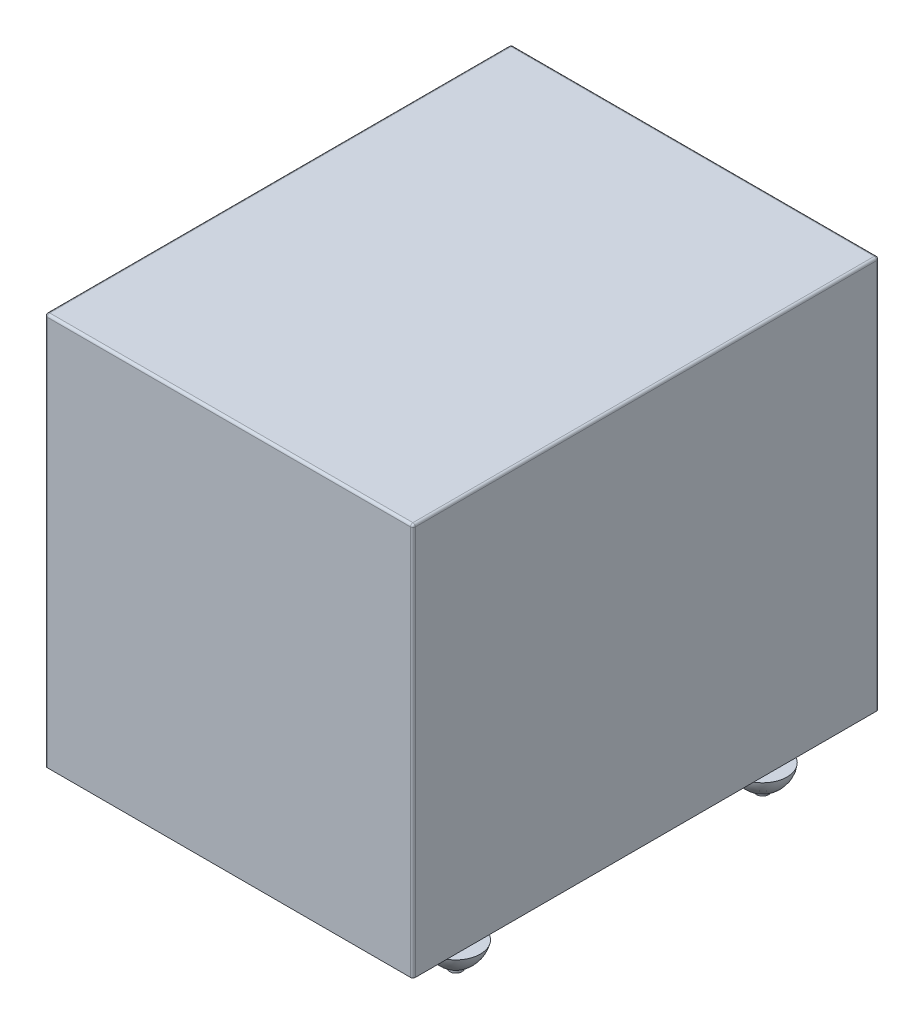
from build123d import *

# Parameters (mm, degrees)
IZIM1_W                     = 15
IZIM1_H                     = 19
Y_KSEKLIK_EKSTR_ZYON1_DEPTH = 16
RADYUS1_R                   = 0.1
IZIM2_R                     = 0.25
Y_KSEKLIK_EKSTR_ZYON2_DEPTH = 2


with BuildPart() as part:
    # Çizim1 → Yükseklik-Ekstrüzyon1 (new body)
    with BuildSketch(Plane(origin=(0, 0, 0), x_dir=(1, 0, 0), z_dir=(0, 1, 0))):
        Rectangle(IZIM1_W, IZIM1_H)
    extrude(amount=Y_KSEKLIK_EKSTR_ZYON1_DEPTH)

    # Radyus1
    radyus1_edges = [part.edges().sort_by_distance(p)[0] for p in [
        (-7.5, 16, 0),
        (0, 16, 9.5),
        (7.5, 16, 0),
        (0, 16, -9.5),
        (7.5, 8, 9.5),
        (-7.5, 8, 9.5),
        (-7.5, 8, -9.5),
        (7.5, 8, -9.5),
    ]]
    fillet(radyus1_edges, radius=RADYUS1_R)

    # Çizim2 → Yükseklik-Ekstrüzyon2 (add)
    with BuildSketch(Plane.XZ):
        with Locations((6, 6.25)):
            Circle(IZIM2_R)
        with Locations((-6, 6.25)):
            Circle(IZIM2_R)
        with Locations((6, -6.25)):
            Circle(IZIM2_R)
        with Locations((-6, -6.25)):
            Circle(IZIM2_R)
        with Locations((0, -8.25)):
            Circle(IZIM2_R)
    extrude(amount=Y_KSEKLIK_EKSTR_ZYON2_DEPTH)

    # Çizim3 → Döndür1 (revolve)
    with BuildSketch(Plane.ZY.offset(6)):
        with BuildLine():
            Line((-6.25, -2), (-6.25, -1))
            Line((-6.25, -1), (-5.25, -1))
            add(Edge.make_bspline(
                [(-6.25, -2), (-5.440038175, -1.628390392), (-5.25, -1)],
                knots=[0, 0, 0, 0.619923651, 0.619923651, 0.619923651], degree=2))
        make_face()
    revolve(axis=Axis((-6, -2, -6.25), (0, 1, 0)))

    # Çizim4 → Döndür2 (revolve)
    with BuildSketch(Plane.ZY.offset(6)):
        with BuildLine():
            Line((6.25, -2), (6.25, -1))
            Line((6.25, -1), (7.25, -1))
            add(Edge.make_bspline(
                [(6.25, -2), (7.064808885, -1.63039811), (7.25, -1)],
                knots=[0, 0, 0, 0.629617769, 0.629617769, 0.629617769], degree=2))
        make_face()
    revolve(axis=Axis((-6, -2, 6.25), (0, 1, 0)))

    # Çizim5 → Döndür3 (revolve)
    with BuildSketch(Plane(origin=(6, 0, 0), x_dir=(0, 0, -1), z_dir=(1, 0, 0))):
        with BuildLine():
            Line((-6.25, -2), (-6.25, -1))
            Line((-6.25, -1), (-7.25, -1))
            add(Edge.make_bspline(
                [(-6.25, -2), (-7.108302041, -1.648413565), (-7.25, -1)],
                knots=[0, 0, 0, 0.716604082, 0.716604082, 0.716604082], degree=2))
        make_face()
    revolve(axis=Axis((6, -2, 6.25), (0, 1, 0)))

    # Çizim6 → Döndür4 (revolve)
    with BuildSketch(Plane(origin=(6, 0, 0), x_dir=(0, 0, -1), z_dir=(1, 0, 0))):
        with BuildLine():
            Line((6.25, -2), (6.25, -1))
            Line((6.25, -1), (7.25, -1))
            add(Edge.make_bspline(
                [(6.25, -2), (7.16916064, -1.673622022), (7.25, -1)],
                knots=[0, 0, 0, 0.838321281, 0.838321281, 0.838321281], degree=2))
        make_face()
    revolve(axis=Axis((6, -2, -6.25), (0, 1, 0)))

    # Çizim7 → Döndür5 (revolve)
    with BuildSketch(Plane(origin=(0, 0, 0), x_dir=(0, 0, -1), z_dir=(1, 0, 0))):
        with BuildLine():
            Line((8.25, -2), (8.25, -1))
            Line((8.25, -1), (9.25, -1))
            add(Edge.make_bspline(
                [(9.25, -1), (8.854156938, -1.651239765), (8.25, -2)],
                knots=[0, 0, 0, 0.716230024, 0.716230024, 0.716230024], degree=2))
        make_face()
    revolve(axis=Axis((0, -2, -8.25), (0, 1, 0)))


solid = part.part
